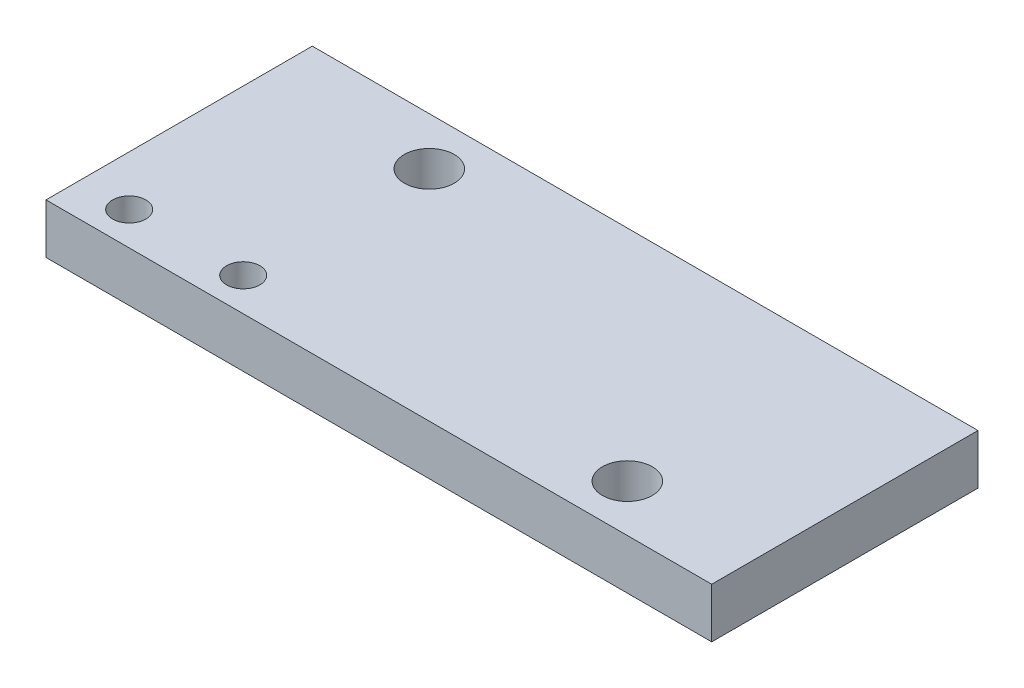
from build123d import *

# Parameters (mm, degrees)
SKETCH1_W           = 40
SKETCH1_H           = 16
SKETCH1_R           = 1.5
BOSS_EXTRUDE1_DEPTH = 3
SKETCH2_R           = 1
CUT_EXTRUDE1_DEPTH  = 10


with BuildPart() as part:
    # Sketch1 → Boss-Extrude1 (new body)
    with BuildSketch(Plane(origin=(0, 0, 0), x_dir=(1, 0, 0), z_dir=(0, 1, 0))):
        with Locations((20, 8)):
            Rectangle(SKETCH1_W, SKETCH1_H)
        with Locations((9.9, 13.13)):
            Circle(SKETCH1_R, mode=Mode.SUBTRACT)
        with Locations((32.1, 2.83)):
            Circle(SKETCH1_R, mode=Mode.SUBTRACT)
    extrude(amount=BOSS_EXTRUDE1_DEPTH)

    # Sketch2 → Cut-Extrude1 (cut)
    with BuildSketch(Plane(origin=(0, 3, 0), x_dir=(1, 0, 0), z_dir=(0, 1, 0))):
        with Locations((3, 2)):
            Circle(SKETCH2_R)
        with Locations((9.85, 2)):
            Circle(SKETCH2_R)
    extrude(amount=-CUT_EXTRUDE1_DEPTH, mode=Mode.SUBTRACT)


solid = part.part
